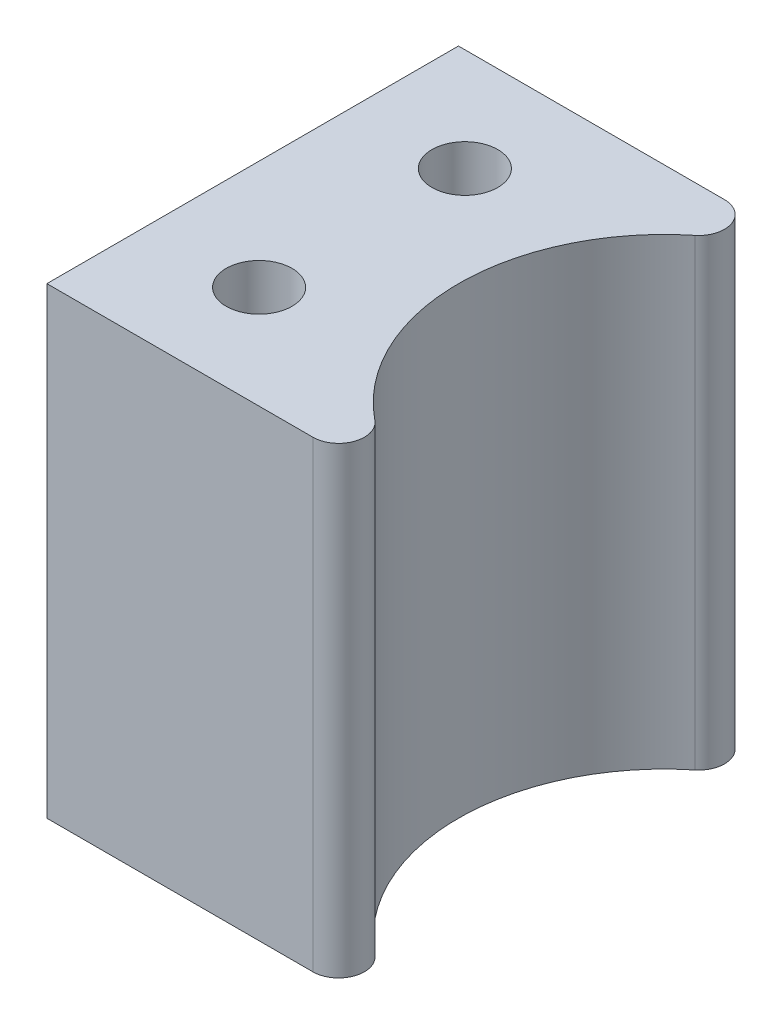
from build123d import *

# Parameters (mm, degrees)
SKETCH3_R           = 2.032
BOSS_EXTRUDE1_DEPTH = 28.575


with BuildPart() as part:
    # Sketch3 → Boss-Extrude1 (new body)
    with BuildSketch(Plane(origin=(0, 0, 0), x_dir=(1, 0, 0), z_dir=(0, 1, 0))):
        with BuildLine():
            Line((-27.78125, 0), (-27.78125, 25.4))
            Line((-27.78125, 25.4), (-11.361506121, 25.4))
            ThreePointArc((-11.361506121, 25.4), (-9.864796768, 24.341666667), (-10.363699885, 22.577777778))
            ThreePointArc((-10.363699885, 22.577777778), (-15.08125, 12.7), (-10.363699885, 2.822222222))
            ThreePointArc((-10.363699885, 2.822222222), (-9.864796768, 1.058333333), (-11.361506121, 0))
            Line((-11.361506121, 0), (-27.78125, 0))
        make_face()
        with Locations((-21.034375, 6.35)):
            Circle(SKETCH3_R, mode=Mode.SUBTRACT)
        with Locations((-21.034375, 19.05)):
            Circle(SKETCH3_R, mode=Mode.SUBTRACT)
    extrude(amount=BOSS_EXTRUDE1_DEPTH)


solid = part.part
